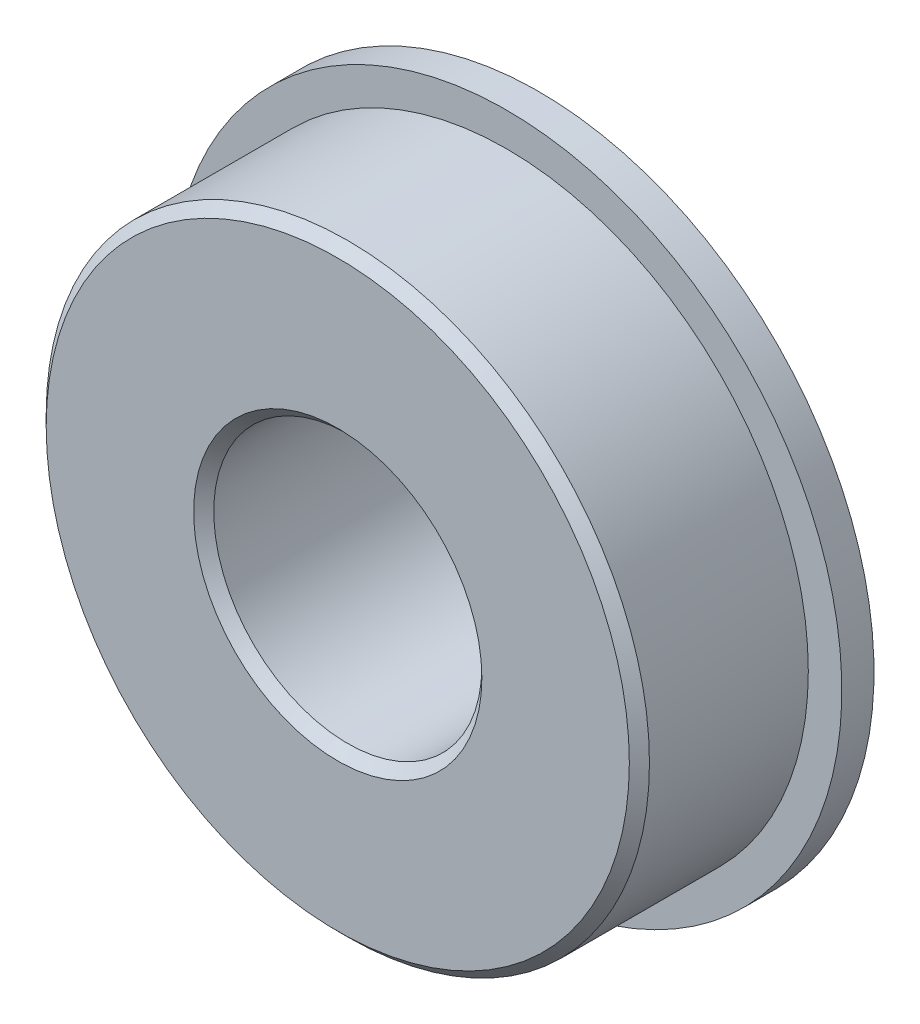
from build123d import *

# Parameters (mm, degrees)
SKETCH6_W           = 1.524
SKETCH6_H           = 5.1562
CIRPATTERN1_COUNT   = 12
SKETCH7_R           = 13.81125
SKETCH7_R_2         = 6.82625
BOSS_EXTRUDE1_DEPTH = 9.525


with BuildPart() as part:
    # Sketch1 → Revolve1 (revolve)
    with BuildSketch(Plane(origin=(0, 0, 0), x_dir=(0, 0, -1), z_dir=(1, 0, 0)), mode=Mode.PRIVATE) as revolve1_sk:
        with BuildLine():
            Line((4.28625, 14.2875), (-4.28625, 14.2875))
            Line((-4.28625, 14.2875), (-4.7625, 13.81125))
            Line((-4.7625, 13.81125), (-4.7625, 10.7188))
            Line((-4.7625, 10.7188), (-2.347405, 10.7188))
            ThreePointArc((-2.347405, 10.7188), (0, 12.7), (2.347405, 10.7188))
            Line((2.347405, 10.7188), (4.7625, 10.7188))
            Line((4.7625, 10.7188), (4.7625, 13.81125))
            Line((4.7625, 13.81125), (4.28625, 14.2875))
        make_face()
    revolve(revolve1_sk.sketch.rotate(Axis((0, 0, 4.7625), (0, 0, -1)), 90), axis=Axis((0, 0, 4.7625), (0, 0, -1)))

    # Sketch6 → Revolve6 (revolve)
    with BuildSketch(Plane(origin=(0, 0, 0), x_dir=(0, 0, -1), z_dir=(1, 0, 0)), mode=Mode.PRIVATE) as revolve6_sk:
        with Locations((4.0005, 13.2969)):
            Rectangle(SKETCH6_W, SKETCH6_H)
    revolve(revolve6_sk.sketch.rotate(Axis((0, 0, -4.7625), (0, 0, 1)), 270), axis=Axis((0, 0, -4.7625), (0, 0, 1)))



with BuildPart() as body_2:
    # Sketch3 → Revolve3 (revolve)
    with BuildSketch(Plane(origin=(0, 0, 0), x_dir=(0, 0, -1), z_dir=(1, 0, 0)), mode=Mode.PRIVATE) as revolve3_sk:
        with BuildLine():
            Line((-4.7625, 6.82625), (-4.7625, 8.26135))
            Line((-4.7625, 8.26135), (-4.28625, 8.7376))
            Line((-4.28625, 8.7376), (-1.780538, 8.7376))
            ThreePointArc((-1.780538, 8.7376), (0, 7.9375), (1.780538, 8.7376))
            Line((1.780538, 8.7376), (5.88645, 8.7376))
            Line((5.88645, 8.7376), (6.3627, 8.26135))
            Line((6.3627, 8.26135), (6.3627, 6.82625))
            Line((6.3627, 6.82625), (5.88645, 6.35))
            Line((5.88645, 6.35), (-4.28625, 6.35))
            Line((-4.28625, 6.35), (-4.7625, 6.82625))
        make_face()
    revolve(revolve3_sk.sketch.rotate(Axis((0, 0, 4.7625), (0, 0, -1)), 90), axis=Axis((0, 0, 4.7625), (0, 0, -1)))


with BuildPart() as body_3:
    # Sketch4 → Revolve4 (revolve)
    with BuildSketch(Plane(origin=(0, 0, 0), x_dir=(0, 0, -1), z_dir=(1, 0, 0))):
        with BuildLine():
            Line((-2.38125, 10.31875), (2.38125, 10.31875))
            ThreePointArc((2.38125, 10.31875), (0, 12.7), (-2.38125, 10.31875))
        make_face()
    revolve(axis=Axis((0, 10.31875, 2.38125), (0, 0, -1)))


with BuildPart() as cirpattern1_1:
    # CirPattern1: pattern copy
    add(body_3.part.rotate(Axis((0, 0, 0), (0, 0, 1)), 1 * 360 / CIRPATTERN1_COUNT))


with BuildPart() as cirpattern1_2:
    # CirPattern1: pattern copy
    add(body_3.part.rotate(Axis((0, 0, 0), (0, 0, 1)), 2 * 360 / CIRPATTERN1_COUNT))


with BuildPart() as cirpattern1_3:
    # CirPattern1: pattern copy
    add(body_3.part.rotate(Axis((0, 0, 0), (0, 0, 1)), 3 * 360 / CIRPATTERN1_COUNT))


with BuildPart() as cirpattern1_4:
    # CirPattern1: pattern copy
    add(body_3.part.rotate(Axis((0, 0, 0), (0, 0, 1)), 4 * 360 / CIRPATTERN1_COUNT))


with BuildPart() as cirpattern1_5:
    # CirPattern1: pattern copy
    add(body_3.part.rotate(Axis((0, 0, 0), (0, 0, 1)), 5 * 360 / CIRPATTERN1_COUNT))


with BuildPart() as cirpattern1_6:
    # CirPattern1: pattern copy
    add(body_3.part.rotate(Axis((0, 0, 0), (0, 0, 1)), 6 * 360 / CIRPATTERN1_COUNT))


with BuildPart() as cirpattern1_7:
    # CirPattern1: pattern copy
    add(body_3.part.rotate(Axis((0, 0, 0), (0, 0, 1)), 7 * 360 / CIRPATTERN1_COUNT))


with BuildPart() as cirpattern1_8:
    # CirPattern1: pattern copy
    add(body_3.part.rotate(Axis((0, 0, 0), (0, 0, 1)), 8 * 360 / CIRPATTERN1_COUNT))


with BuildPart() as cirpattern1_9:
    # CirPattern1: pattern copy
    add(body_3.part.rotate(Axis((0, 0, 0), (0, 0, 1)), 9 * 360 / CIRPATTERN1_COUNT))


with BuildPart() as cirpattern1_10:
    # CirPattern1: pattern copy
    add(body_3.part.rotate(Axis((0, 0, 0), (0, 0, 1)), 10 * 360 / CIRPATTERN1_COUNT))


with BuildPart() as cirpattern1_11:
    # CirPattern1: pattern copy
    add(body_3.part.rotate(Axis((0, 0, 0), (0, 0, 1)), 11 * 360 / CIRPATTERN1_COUNT))


with BuildPart() as part_1:
    add(part.part)

    add(body_2.part)  # Boss-Extrude1 merges body 2

    add(body_3.part)  # Boss-Extrude1 merges body 3

    add(cirpattern1_1.part)  # Boss-Extrude1 merges CirPattern1_1

    add(cirpattern1_2.part)  # Boss-Extrude1 merges CirPattern1_2

    add(cirpattern1_3.part)  # Boss-Extrude1 merges CirPattern1_3

    add(cirpattern1_4.part)  # Boss-Extrude1 merges CirPattern1_4

    add(cirpattern1_5.part)  # Boss-Extrude1 merges CirPattern1_5

    add(cirpattern1_6.part)  # Boss-Extrude1 merges CirPattern1_6

    add(cirpattern1_7.part)  # Boss-Extrude1 merges CirPattern1_7

    add(cirpattern1_8.part)  # Boss-Extrude1 merges CirPattern1_8

    add(cirpattern1_9.part)  # Boss-Extrude1 merges CirPattern1_9

    add(cirpattern1_10.part)  # Boss-Extrude1 merges CirPattern1_10

    add(cirpattern1_11.part)  # Boss-Extrude1 merges CirPattern1_11
    # Sketch7 → Boss-Extrude1 (add)
    with BuildSketch(Plane.XY.offset(4.7625)):
        Circle(SKETCH7_R)
        Circle(SKETCH7_R_2, mode=Mode.SUBTRACT)
    extrude(amount=-BOSS_EXTRUDE1_DEPTH)


solid = part_1.part
